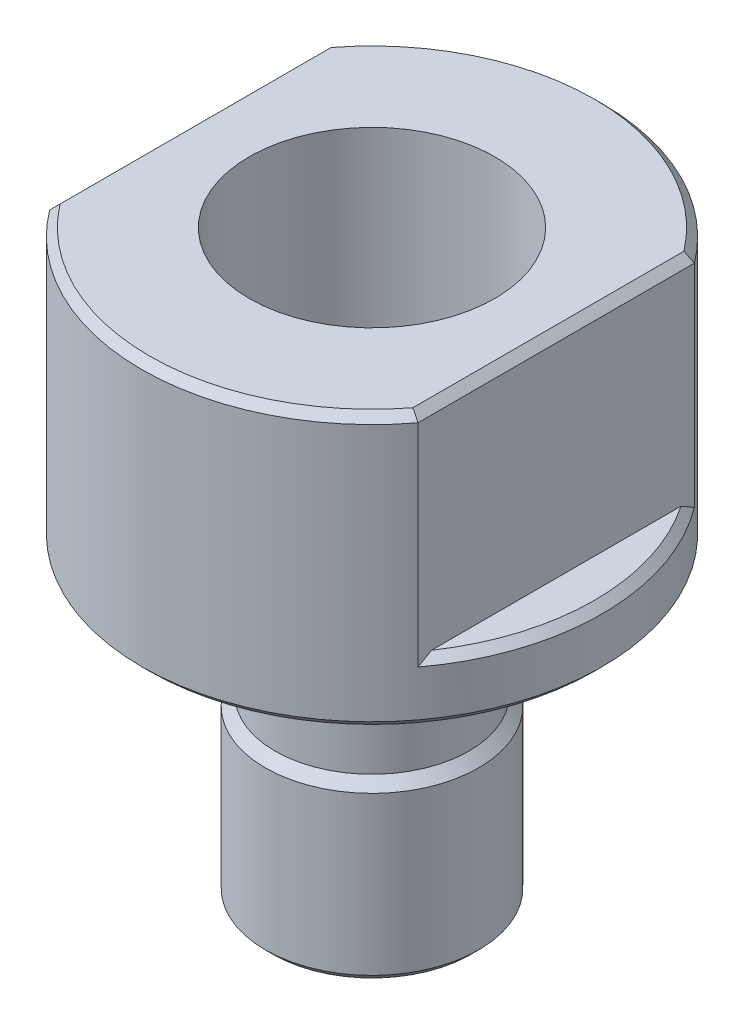
from build123d import *

# Parameters (mm, degrees)
SKETCH2_W          = 20.13485227
SKETCH2_H          = 29.427861008
SKETCH2_W_2        = 12
SKETCH2_H_2        = 20.553456266
CUT_EXTRUDE1_DEPTH = 6.89
CHAMFER2_SIZE      = 0.254
CHAMFER4_SIZE      = 0.254
CHAMFER5_SIZE      = 0.254


with BuildPart() as part:
    # Sketch1 → Revolve1 (revolve)
    with BuildSketch(Plane.XY):
        Polygon((7.5, 0), (7.5, -8.89), (3.475, -8.89), (3.475, -10.89), (3.159135291, -11.205864709), (3.159135291, -13.185864709), (3.475, -13.501729418), (3.475, -18.89), (2.0381, -18.89), (2.0381, -8.0269), (3.175, -6.89), (4, -6.89), (4, 0), align=None)
    revolve(axis=Axis((0, 0, 0), (0, -1, 0)))

    # Sketch2 → Cut-Extrude1 (cut)
    with BuildSketch(Plane(origin=(0, 0, 0), x_dir=(1, 0, 0), z_dir=(0, 1, 0))):
        Rectangle(SKETCH2_W, SKETCH2_H)
        Rectangle(SKETCH2_W_2, SKETCH2_H_2, mode=Mode.SUBTRACT)
    extrude(amount=-CUT_EXTRUDE1_DEPTH, mode=Mode.SUBTRACT)

    # Chamfer2
    chamfer2_edges = [part.edges().sort_by_distance(p)[0] for p in [
        (-3.475, -18.89, 0),
        (-7.5, -8.89, 0),
    ]]
    chamfer(chamfer2_edges, length=CHAMFER2_SIZE)

    # Chamfer4
    chamfer4_edges = [part.edges().sort_by_distance(p)[0] for p in [
        (0, 0, -7.5),
        (0, 0, 7.5),
        (6, 0, 0),
        (-6, 0, 0),
    ]]
    chamfer(chamfer4_edges, length=CHAMFER4_SIZE)

    # Chamfer5
    chamfer5_edges = [part.edges().sort_by_distance(p)[0] for p in [
        (-7.5, -6.89, 0),
        (7.115124735, -6.89, 2.371708245),
    ]]
    chamfer(chamfer5_edges, length=CHAMFER5_SIZE)


solid = part.part
